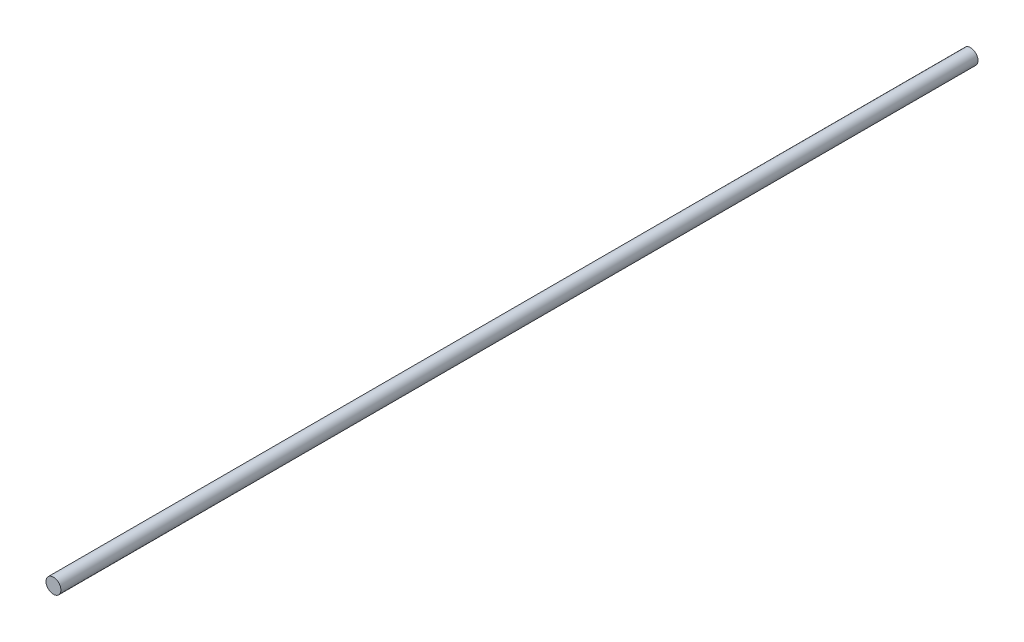
from build123d import *

# Parameters (mm, degrees)
SKETCH1_R           = 5
BOSS_EXTRUDE1_DEPTH = 307.5


with BuildPart() as part:
    # Sketch1 → Boss-Extrude1 (new body, symmetric)
    with BuildSketch(Plane.XY):
        Circle(SKETCH1_R)
    extrude(amount=BOSS_EXTRUDE1_DEPTH, both=True)


solid = part.part
